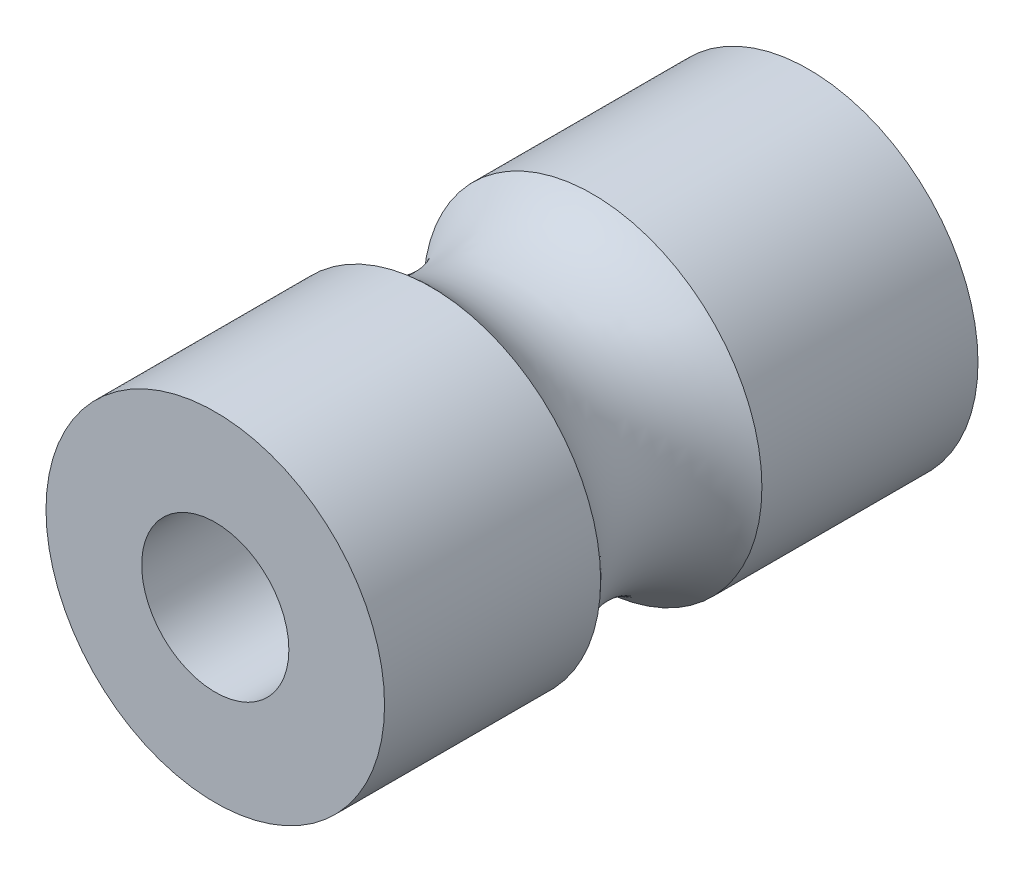
from build123d import *

# Parameters (mm, degrees)
EXTRUDE1_START              = -16
SKETCH1_R                   = 9.128125
EXTRUDE1_DEPTH              = 32
F_3_8_16_TAPPED_HOLE3_D     = 7.9375
F_3_8_16_TAPPED_HOLE3_DEPTH = 14.762
F_3_8_16_TAPPED_HOLE3_TIP   = 2.384665582
F_3_8_16_TAPPED_HOLE4_D     = 7.9375
F_3_8_16_TAPPED_HOLE4_DEPTH = 14.762
F_3_8_16_TAPPED_HOLE4_TIP   = 2.384665582


with BuildPart() as part:
    # Sketch1 → Extrude1 (new body)
    with BuildSketch(Plane.XY.offset(EXTRUDE1_START)):
        Circle(SKETCH1_R)
    extrude(amount=EXTRUDE1_DEPTH)

    # Sketch2 → Cut-Revolve1 (revolve, cut)
    with BuildSketch(Plane(origin=(0, 0, 0), x_dir=(0, 0, -1), z_dir=(1, 0, 0))):
        with BuildLine():
            Line((-6, 13.2625), (-6, 15.153312549))
            Line((-6, 15.153312549), (6, 15.153312549))
            Line((6, 15.153312549), (6, 13.2625))
            ThreePointArc((6, 13.2625), (0, 7.2625), (-6, 13.2625))
        make_face()
    revolve(axis=Axis((0, 0, 16), (0, 0, -1)), mode=Mode.SUBTRACT)

    # 3_8-16 Tapped Hole3
    with Locations(Plane.XY.offset(16)):
        with Locations((0, 0)):
            Hole(F_3_8_16_TAPPED_HOLE3_D / 2, depth=F_3_8_16_TAPPED_HOLE3_DEPTH)
            with Locations((0, 0, -(F_3_8_16_TAPPED_HOLE3_DEPTH + F_3_8_16_TAPPED_HOLE3_TIP / 2))):  # 118° drill point
                Cone(0, F_3_8_16_TAPPED_HOLE3_D / 2, F_3_8_16_TAPPED_HOLE3_TIP, mode=Mode.SUBTRACT)

    # 3_8-16 Tapped Hole4
    with Locations(Plane(origin=(0, 0, -16), x_dir=(-1, 0, 0), z_dir=(0, 0, -1))):
        with Locations((0, 0)):
            Hole(F_3_8_16_TAPPED_HOLE4_D / 2, depth=F_3_8_16_TAPPED_HOLE4_DEPTH)
            with Locations((0, 0, -(F_3_8_16_TAPPED_HOLE4_DEPTH + F_3_8_16_TAPPED_HOLE4_TIP / 2))):  # 118° drill point
                Cone(0, F_3_8_16_TAPPED_HOLE4_D / 2, F_3_8_16_TAPPED_HOLE4_TIP, mode=Mode.SUBTRACT)


solid = part.part
